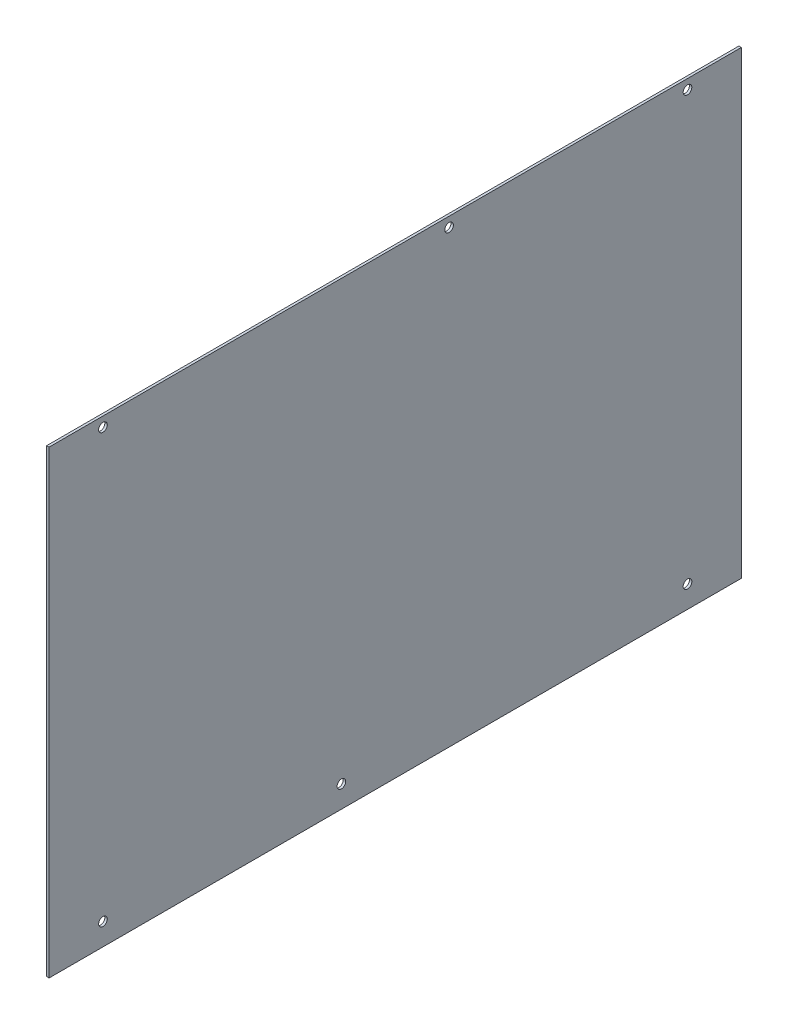
from build123d import *

# Parameters (mm, degrees)
SKETCH2_W                  = 450
SKETCH2_H                  = 298.8966167
BOSS_EXTRUDE1_DEPTH        = 1.6002
F_10_CLEARANCE_HOLE1_D     = 5.6134
F_10_CLEARANCE_HOLE1_DEPTH = 20
F_10_CLEARANCE_HOLE1_TIP   = 1.686435499


with BuildPart() as part:
    # Sketch2 → Boss-Extrude1 (new body)
    with BuildSketch(Plane(origin=(0, 0, 0), x_dir=(0, 0, -1), z_dir=(1, 0, 0))):
        with Locations((0, -3.9624)):
            Rectangle(SKETCH2_W, SKETCH2_H)
    extrude(amount=BOSS_EXTRUDE1_DEPTH)

    # #10 Clearance Hole1
    with Locations(Plane.ZY):
        with Locations((-190, 139.12320835), (-35, 139.12320835), (190, 139.12320835), (190, -139.12320835), (35, -139.12320835), (-190, -139.12320835)):
            Hole(F_10_CLEARANCE_HOLE1_D / 2, depth=F_10_CLEARANCE_HOLE1_DEPTH)
            with Locations((0, 0, -(F_10_CLEARANCE_HOLE1_DEPTH + F_10_CLEARANCE_HOLE1_TIP / 2))):  # 118° drill point
                Cone(0, F_10_CLEARANCE_HOLE1_D / 2, F_10_CLEARANCE_HOLE1_TIP, mode=Mode.SUBTRACT)


solid = part.part
